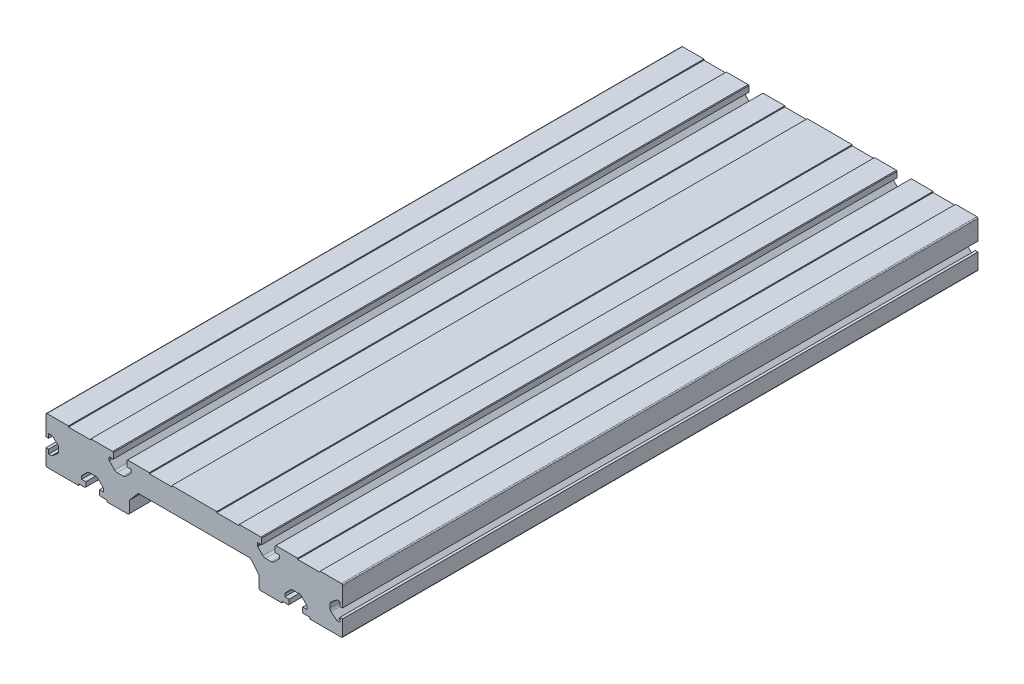
from build123d import *

# Parameters (mm, degrees)
Y_KSEKLIK_EKSTR_ZYON1_DEPTH = 300


with BuildPart() as part:
    # Çizim1 → Yükseklik-Ekstrüzyon1 (new body)
    with BuildSketch(Plane.XY):
        with BuildLine():
            Line((0.5, 0), (15.3, 0))
            Line((15.3, 0), (15.3, 0.75))
            Line((15.3, 0.75), (18.5, 0.75))
            Line((18.5, 0.75), (18.8, 1.05))
            Line((18.8, 1.05), (18.8, 3.25))
            Line((18.8, 3.25), (16.8, 3.25))
            Line((16.8, 3.25), (16.8, 4.542893219))
            ThreePointArc((16.8, 4.542893219), (16.838060234, 4.734234935), (16.946446609, 4.896446609))
            Line((16.946446609, 4.896446609), (19.401845417, 7.351845417))
            ThreePointArc((19.401845417, 7.351845417), (19.969586278, 7.731197732), (20.639282284, 7.86440855))
            Line((20.639282284, 7.86440855), (23.360717716, 7.86440855))
            ThreePointArc((23.360717716, 7.86440855), (24.030413722, 7.731197732), (24.598154583, 7.351845417))
            Line((24.598154583, 7.351845417), (27.053553391, 4.896446609))
            ThreePointArc((27.053553391, 4.896446609), (27.161939766, 4.734234935), (27.2, 4.542893219))
            Line((27.2, 4.542893219), (27.2, 3.25))
            Line((27.2, 3.25), (25.2, 3.25))
            Line((25.2, 3.25), (25.2, 1.05))
            Line((25.2, 1.05), (25.5, 0.75))
            Line((25.5, 0.75), (28.7, 0.75))
            Line((28.7, 0.75), (28.7, 0))
            Line((28.7, 0), (38.882330038, 0))
            Line((38.882330038, 0), (39.482330038, 0.6))
            Line((39.482330038, 0.6), (39.482330038, 6.1))
            Line((39.482330038, 6.1), (43.5, 10.888072611))
            Line((43.5, 10.888072611), (96.5, 10.888072611))
            Line((96.5, 10.888072611), (100.517669962, 6.1))
            Line((100.517669962, 6.1), (100.517669962, 0.6))
            Line((100.517669962, 0.6), (101.117669962, 0))
            Line((101.117669962, 0), (111.3, 0))
            Line((111.3, 0), (111.3, 0.75))
            Line((111.3, 0.75), (114.5, 0.75))
            Line((114.5, 0.75), (114.8, 1.05))
            Line((114.8, 1.05), (114.8, 3.25))
            Line((114.8, 3.25), (112.8, 3.25))
            Line((112.8, 3.25), (112.8, 4.542893219))
            ThreePointArc((112.8, 4.542893219), (112.838060234, 4.734234935), (112.946446609, 4.896446609))
            Line((112.946446609, 4.896446609), (115.401845417, 7.351845417))
            ThreePointArc((115.401845417, 7.351845417), (115.969586278, 7.731197732), (116.639282284, 7.86440855))
            Line((116.639282284, 7.86440855), (119.360717716, 7.86440855))
            ThreePointArc((119.360717716, 7.86440855), (120.030413722, 7.731197732), (120.598154583, 7.351845417))
            Line((120.598154583, 7.351845417), (123.053553391, 4.896446609))
            ThreePointArc((123.053553391, 4.896446609), (123.161939766, 4.734234935), (123.2, 4.542893219))
            Line((123.2, 4.542893219), (123.2, 3.25))
            Line((123.2, 3.25), (121.2, 3.25))
            Line((121.2, 3.25), (121.2, 1.05))
            Line((121.2, 1.05), (121.5, 0.75))
            Line((121.5, 0.75), (124.7, 0.75))
            Line((124.7, 0.75), (124.7, 0))
            Line((124.7, 0), (139.5, 0))
            ThreePointArc((139.5, 0), (139.853553391, 0.146446609), (140, 0.5))
            Line((140, 0.5), (140, 7.8))
            Line((140, 7.8), (138.75, 7.8))
            Line((138.75, 7.8), (138.75, 5.8))
            Line((138.75, 5.8), (137.431985117, 5.8))
            ThreePointArc((137.431985117, 5.8), (137.260975045, 5.83015369), (137.110591312, 5.916977778))
            Line((137.110591312, 5.916977778), (134.625121683, 8.002534428))
            ThreePointArc((134.625121683, 8.002534428), (134.163961373, 8.603530245), (134, 9.343112203))
            Line((134, 9.343112203), (134, 10.698544282))
            ThreePointArc((134, 10.698544282), (134.163961373, 11.43812624), (134.625121683, 12.039122058))
            Line((134.625121683, 12.039122058), (137.110591312, 14.124678707))
            ThreePointArc((137.110591312, 14.124678707), (137.260975045, 14.211502796), (137.431985117, 14.241656485))
            Line((137.431985117, 14.241656485), (138.75, 14.241656485))
            Line((138.75, 14.241656485), (138.75, 12.241656485))
            Line((138.75, 12.241656485), (140, 12.241656485))
            Line((140, 12.241656485), (140, 21.5))
            ThreePointArc((140, 21.5), (139.853553391, 21.853553391), (139.5, 22))
            Line((139.5, 22), (129.4, 22))
            Line((129.4, 22), (129.4, 21.5))
            Line((129.4, 21.5), (118.8, 21.5))
            Line((118.8, 21.5), (118.8, 22))
            Line((118.8, 22), (108.5, 22))
            Line((108.5, 22), (108.2, 21.7))
            Line((108.2, 21.7), (108.2, 19))
            Line((108.2, 19), (110.2, 19))
            Line((110.2, 19), (110.2, 17.707106781))
            ThreePointArc((110.2, 17.707106781), (110.161939766, 17.515765065), (110.053553391, 17.353553391))
            Line((110.053553391, 17.353553391), (107.598154583, 14.898154583))
            ThreePointArc((107.598154583, 14.898154583), (107.030413722, 14.518802268), (106.360717716, 14.38559145))
            Line((106.360717716, 14.38559145), (103.639282284, 14.38559145))
            ThreePointArc((103.639282284, 14.38559145), (102.969586278, 14.518802268), (102.401845417, 14.898154583))
            Line((102.401845417, 14.898154583), (99.946446609, 17.353553391))
            ThreePointArc((99.946446609, 17.353553391), (99.86234478, 17.525824053), (99.8, 17.707106781))
            Line((99.8, 17.707106781), (99.8, 19))
            Line((99.8, 19), (101.8, 19))
            Line((101.8, 19), (101.8, 21.7))
            Line((101.8, 21.7), (101.5, 22))
            Line((101.5, 22), (91.2, 22))
            Line((91.2, 22), (91.2, 21.5))
            Line((91.2, 21.5), (80.6, 21.5))
            Line((80.6, 21.5), (80.6, 22))
            Line((80.6, 22), (59.4, 22))
            Line((59.4, 22), (59.4, 21.5))
            Line((59.4, 21.5), (48.8, 21.5))
            Line((48.8, 21.5), (48.8, 22))
            Line((48.8, 22), (38.5, 22))
            Line((38.5, 22), (38.2, 21.7))
            Line((38.2, 21.7), (38.2, 19))
            Line((38.2, 19), (40.2, 19))
            Line((40.2, 19), (40.2, 17.707106781))
            ThreePointArc((40.2, 17.707106781), (40.13765522, 17.525824053), (40.053553391, 17.353553391))
            Line((40.053553391, 17.353553391), (37.598154583, 14.898154583))
            ThreePointArc((37.598154583, 14.898154583), (37.030413722, 14.518802268), (36.360717716, 14.38559145))
            Line((36.360717716, 14.38559145), (33.639282284, 14.38559145))
            ThreePointArc((33.639282284, 14.38559145), (32.969586278, 14.518802268), (32.401845417, 14.898154583))
            Line((32.401845417, 14.898154583), (29.946446609, 17.353553391))
            ThreePointArc((29.946446609, 17.353553391), (29.838060234, 17.515765065), (29.8, 17.707106781))
            Line((29.8, 17.707106781), (29.8, 19))
            Line((29.8, 19), (31.8, 19))
            Line((31.8, 19), (31.8, 21.7))
            Line((31.8, 21.7), (31.5, 22))
            Line((31.5, 22), (21.2, 22))
            Line((21.2, 22), (21.2, 21.5))
            Line((21.2, 21.5), (10.6, 21.5))
            Line((10.6, 21.5), (10.6, 22))
            Line((10.6, 22), (0.5, 22))
            ThreePointArc((0.5, 22), (0.146446609, 21.853553391), (0, 21.5))
            Line((0, 21.5), (0, 12.241656485))
            Line((0, 12.241656485), (1.25, 12.241656485))
            Line((1.25, 12.241656485), (1.25, 14.241656485))
            Line((1.25, 14.241656485), (2.568014883, 14.241656485))
            ThreePointArc((2.568014883, 14.241656485), (2.739024955, 14.211502796), (2.889408688, 14.124678707))
            Line((2.889408688, 14.124678707), (5.374878317, 12.039122058))
            ThreePointArc((5.374878317, 12.039122058), (5.836038627, 11.43812624), (6, 10.698544282))
            Line((6, 10.698544282), (6, 9.343112203))
            ThreePointArc((6, 9.343112203), (5.836038627, 8.603530245), (5.374878317, 8.002534428))
            Line((5.374878317, 8.002534428), (2.889408688, 5.916977778))
            ThreePointArc((2.889408688, 5.916977778), (2.739024955, 5.83015369), (2.568014883, 5.8))
            Line((2.568014883, 5.8), (1.25, 5.8))
            Line((1.25, 5.8), (1.25, 7.8))
            Line((1.25, 7.8), (0, 7.8))
            Line((0, 7.8), (0, 0.5))
            ThreePointArc((0, 0.5), (0.146446609, 0.146446609), (0.5, 0))
        make_face()
    extrude(amount=Y_KSEKLIK_EKSTR_ZYON1_DEPTH)


solid = part.part
